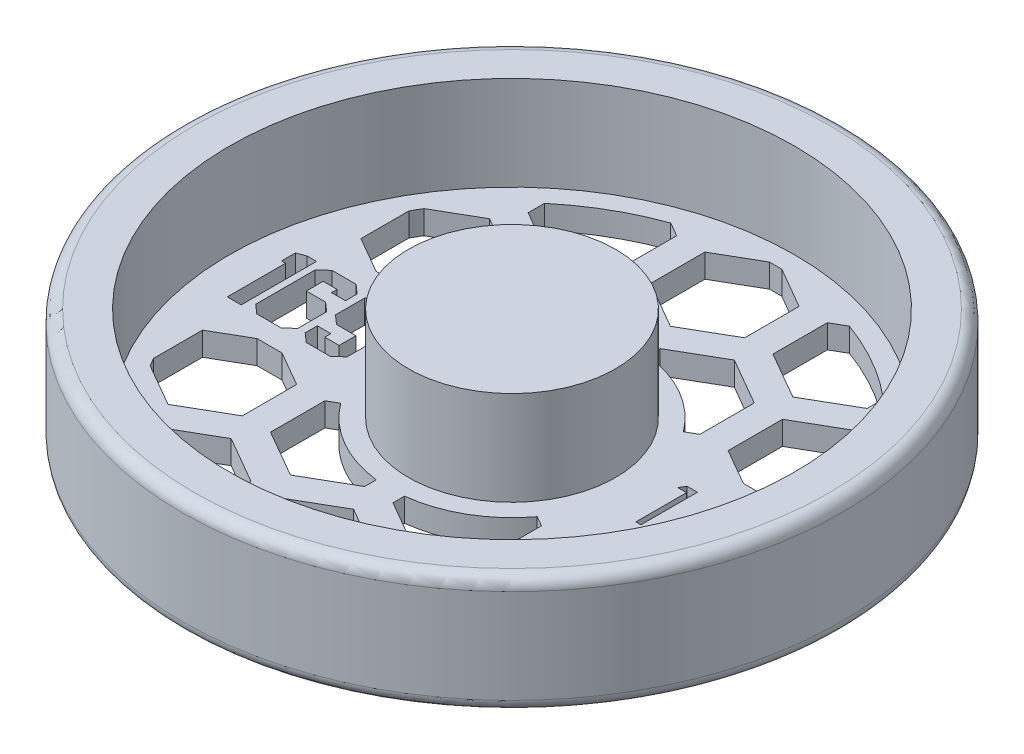
from build123d import *

# Parameters (mm, degrees)
SKETCH2_W               = 1.935420596
SKETCH2_H               = 2.263100716
SKETCH2_W_2             = 1.881765372
CUT_EXTRUDE1_DEPTH      = 65.131856448
CUT_EXTRUDE1_DEPTH_BACK = 65.131856448
CUT_EXTRUDE4_DEPTH      = 65.131856448
CUT_EXTRUDE4_DEPTH_BACK = 65.131856448


with BuildPart() as part:
    # Sketch1 → Revolve1 (revolve)
    with BuildSketch(Plane.XY, mode=Mode.PRIVATE) as revolve1_sk:
        with BuildLine():
            Line((0, 0), (0, 15.875))
            Line((0, 15.875), (13.97, 15.875))
            Line((13.97, 15.875), (13.97, 3.175))
            Line((13.97, 3.175), (38.1, 3.175))
            Line((38.1, 3.175), (38.1, 15.875))
            Line((38.1, 15.875), (42.8625, 15.875))
            ThreePointArc((42.8625, 15.875), (43.985032015, 15.410032015), (44.45, 14.2875))
            Line((44.45, 14.2875), (44.45, 1.5875))
            ThreePointArc((44.45, 1.5875), (43.985032015, 0.464967985), (42.8625, 0))
            Line((42.8625, 0), (0, 0))
        make_face()
    revolve(revolve1_sk.sketch.rotate(Axis((0, 0, 0), (0, 1, 0)), 90), axis=Axis((0, 0, 0), (0, 1, 0)))

    # Sketch2 → Cut-Extrude1 (cut, two sides)
    with BuildSketch(Plane(origin=(0, 3.175, 0), x_dir=(1, 0, 0), z_dir=(0, 1, 0))) as cut_extrude1_sk:
        Polygon((-18.235829876, -4.018393059), (-19.437323651, -5.08), (-22.671967182, -5.08), (-23.875377216, -4.018393059), (-23.875377216, -2.383824972), (-22.045350811, -2.383824972), (-22.045350811, -3.203983402), (-20.109930215, -3.203983402), (-20.109930215, -0.940882686), (-22.729454923, -0.940882686), (-23.927116183, 0.120724255), (-23.927116183, 4.012644285), (-22.729454923, 5.08), (-19.450737458, 5.08), (-18.235829876, 4.006895511), align=None)
        with Locations((-21.077640513, 2.072433044)):
            Rectangle(SKETCH2_W, SKETCH2_H, mode=Mode.SUBTRACT)
        Polygon((-24.883328932, -4.018393059), (-26.086738966, -5.08), (-29.346293851, -5.08), (-30.549703885, -4.018393059), (-30.549703885, 4.012644285), (-29.359707657, 5.08), (-26.105901547, 5.08), (-24.902491513, 4.012644285), (-24.902491513, 2.441312712), (-26.784256884, 2.441312712), (-26.784256884, 3.203983402), (-28.673687288, 3.203983402), (-28.673687288, 0.940882686), (-26.086738966, 0.940882686), (-24.883328932, -0.113059223), align=None)
        with Locations((-27.732804602, -2.072433044)):
            Rectangle(SKETCH2_W_2, SKETCH2_H, mode=Mode.SUBTRACT)
        Polygon((-31.448428895, -5.08), (-33.324445492, -5.08), (-33.324445492, 2.770909091), (-33.860997737, 2.770909091), (-33.860997737, 4.646925688), (-32.703577895, 5.08), (-31.448428895, 5.08), align=None)
        Polygon((19.790324519, 3.81), (21.199230769, 3.81), (21.199230769, -3.81), (20.515384615, -3.81), (20.515384615, 3.028461538), (19.343076923, 3.028461538), align=None)
        Polygon((28.037692308, 4.005384615), (24.850480769, -4.884615385), (24.13, -4.884615385), (27.317211538, 4.005384615), align=None)
        with BuildLine():
            Line((29.600769231, 1.465384615), (28.916923077, 1.465384615))
            add(Edge.make_bspline(
                [(28.916923077, 1.465384615), (28.921380021, 1.556108091), (28.930133342, 1.734286583), (28.971125217, 1.994071773), (29.029779356, 2.242385364), (29.112709893, 2.477233576), (29.215702418, 2.700692922), (29.339211791, 2.911875814), (29.485502403, 3.10997663), (29.65141535, 3.293158912), (29.831614501, 3.46120728), (30.026046289, 3.606325266), (30.23036032, 3.728936882), (30.443936726, 3.831439471), (30.669185153, 3.908379365), (30.904061546, 3.96546762), (31.149597838, 3.999814978), (31.316889543, 4.003506946), (31.401971154, 4.005384615)],
                knots=[0, 0, 0, 0, 1.10065271, 2.161652631, 3.183658789, 4.190468796, 5.17591951, 6.163126047, 7.15150782, 8.156236427, 9.156009102, 10.134482811, 11.092018607, 12.041330605, 13.001268258, 13.972401359, 14.968799086, 16, 16, 16, 16], degree=3))
            add(Edge.make_bspline(
                [(31.401971154, 4.005384615), (31.485525704, 4.003428547), (31.64970741, 3.999584944), (31.889328138, 3.966577217), (32.117443276, 3.914879672), (32.333606928, 3.842347251), (32.536094417, 3.744845155), (32.726426874, 3.627720228), (32.906870239, 3.492258766), (33.069299865, 3.33277475), (33.218451741, 3.162516987), (33.347125793, 2.980751894), (33.457317881, 2.79301842), (33.549166487, 2.597885022), (33.616780138, 2.393514383), (33.668113265, 2.182881901), (33.697128948, 1.963807313), (33.701582128, 1.815529611), (33.703846154, 1.740144231)],
                knots=[0, 0, 0, 0, 1.111607364, 2.184268762, 3.212621178, 4.221274766, 5.211760367, 6.196651075, 7.1921475, 8.207485113, 9.220403448, 10.201281604, 11.166441695, 12.114753415, 13.065576456, 14.026450734, 14.996634279, 16, 16, 16, 16], degree=3))
            add(Edge.make_bspline(
                [(33.703846154, 1.740144231), (33.700159679, 1.634013231), (33.692851421, 1.42361368), (33.630336121, 1.114427036), (33.53269886, 0.814866506), (33.4151389, 0.57377558), (33.296544607, 0.379501517), (33.189674091, 0.21954965), (33.064564988, 0.047325745), (32.919396373, -0.136593487), (32.757171205, -0.333648657), (32.576420095, -0.543720726), (32.375854114, -0.764639265), (32.235083321, -0.91552746), (32.162139423, -0.993713942)],
                knots=[0, 0, 0, 0, 1.184426356, 2.348067706, 3.509069118, 4.696110526, 5.333549288, 6.050745305, 6.844228056, 7.710549037, 8.667450064, 9.695053472, 10.805634456, 12, 12, 12, 12], degree=3))
            Line((32.162139423, -0.993713942), (30.255612981, -3.028461538))
            Line((30.255612981, -3.028461538), (33.801538462, -3.028461538))
            Line((33.801538462, -3.028461538), (33.801538462, -3.81))
            Line((33.801538462, -3.81), (28.623846154, -3.81))
            Line((28.623846154, -3.81), (31.579038462, -0.656370192))
            add(Edge.make_bspline(
                [(31.579038462, -0.656370192), (31.650988432, -0.581262451), (31.789189601, -0.43699585), (31.984659097, -0.226372605), (32.160221694, -0.030975034), (32.317013846, 0.14882768), (32.451634221, 0.315665551), (32.571098909, 0.464135162), (32.666818281, 0.600760566), (32.770701514, 0.759127274), (32.871315954, 0.952484376), (32.957775426, 1.188777722), (33.01049461, 1.432023912), (33.016818852, 1.596402633), (33.02, 1.679086538)],
                knots=[0, 0, 0, 0, 1.329631726, 2.553950428, 3.673215718, 4.687767853, 5.603093632, 6.413772471, 7.123043292, 7.734684054, 8.834405432, 9.900288307, 10.943827018, 12, 12, 12, 12], degree=3))
            add(Edge.make_bspline(
                [(33.02, 1.679086538), (33.018615898, 1.731079754), (33.015888099, 1.833548399), (32.991813912, 1.983783794), (32.955432753, 2.128704903), (32.903300506, 2.268757497), (32.834488117, 2.402533459), (32.750726073, 2.530195631), (32.654082564, 2.653615606), (32.542283514, 2.769337929), (32.419467577, 2.875323868), (32.289722382, 2.969211163), (32.152453298, 3.047673455), (32.008239089, 3.111993869), (31.85748181, 3.162449985), (31.699889879, 3.197411806), (31.535898735, 3.219362814), (31.423920667, 3.222332811), (31.366862981, 3.223846154)],
                knots=[0, 0, 0, 0, 0.991446411, 1.95395049, 2.89581595, 3.838931463, 4.798493298, 5.75982156, 6.748411868, 7.785213223, 8.824556874, 9.840280684, 10.836137867, 11.835679398, 12.848801643, 13.863922112, 14.911575587, 16, 16, 16, 16], degree=3))
            add(Edge.make_bspline(
                [(31.366862981, 3.223846154), (31.307272768, 3.222289426), (31.190247429, 3.219232271), (31.01842942, 3.197846928), (30.854521527, 3.160953413), (30.698111441, 3.110494482), (30.548934514, 3.046359013), (30.407716224, 2.966475843), (30.274773591, 2.871152923), (30.149856703, 2.763078341), (30.034764268, 2.642752877), (29.933642784, 2.508619186), (29.845285588, 2.363126356), (29.768194628, 2.206666963), (29.705589383, 2.037821305), (29.657750695, 1.857188759), (29.619897046, 1.665553637), (29.607251067, 1.533215824), (29.600769231, 1.465384615)],
                knots=[0, 0, 0, 0, 1.031018746, 2.02475058, 2.990194455, 3.934040569, 4.864654155, 5.795059489, 6.735614925, 7.690564532, 8.649604399, 9.611025574, 10.590972636, 11.591080095, 12.624614302, 13.701020113, 14.821632451, 16, 16, 16, 16], degree=3))
        make_face()
    extrude(amount=CUT_EXTRUDE1_DEPTH, mode=Mode.SUBTRACT)
    extrude(cut_extrude1_sk.sketch, amount=-CUT_EXTRUDE1_DEPTH_BACK, mode=Mode.SUBTRACT)


with BuildPart() as body_2:
    # of the pieces the cut leaves, the one that is kept (cut_extrude1_keep)
    add(part.part.solids().sort_by_distance((0, 0, -42.8625))[0])

    # Sketch3 → Cut-Extrude4 (cut, two sides)
    with BuildSketch(Plane(origin=(0, 3.175, 0), x_dir=(1, 0, 0), z_dir=(0, 1, 0))) as cut_extrude4_sk:
        with BuildLine():
            ThreePointArc((-1.905, -16.399727894), (-8.255, -14.298079416), (-13.250080971, -9.849642341))
            Line((-13.250080971, -9.849642341), (-14.605, -10.631905207))
            Line((-14.605, -10.631905207), (-14.605, -17.964253626))
            Line((-14.605, -17.964253626), (-8.255, -21.630427835))
            Line((-8.255, -21.630427835), (-1.905, -17.964253626))
            Line((-1.905, -17.964253626), (-1.905, -16.399727894))
        make_face()
        with BuildLine():
            Line((14.605, -10.631905207), (13.250080971, -9.849642341))
            ThreePointArc((13.250080971, -9.849642341), (8.255, -14.298079416), (1.905, -16.399727894))
            Line((1.905, -16.399727894), (1.905, -17.964253626))
            Line((1.905, -17.964253626), (8.255, -21.630427835))
            Line((8.255, -21.630427835), (14.605, -17.964253626))
            Line((14.605, -17.964253626), (14.605, -10.631905207))
        make_face()
        with BuildLine():
            Line((-18.415, -10.631905207), (-23.081846715, -7.9375))
            Line((-23.081846715, -7.9375), (-26.448153285, -7.9375))
            Line((-26.448153285, -7.9375), (-31.115, -10.631905207))
            Line((-31.115, -10.631905207), (-31.115, -17.215410974))
            ThreePointArc((-31.115, -17.215410974), (-30.795863359, -17.78), (-30.46648324, -18.338674952))
            Line((-30.46648324, -18.338674952), (-24.765, -21.630427835))
            Line((-24.765, -21.630427835), (-18.415, -17.964253626))
            Line((-18.415, -17.964253626), (-18.415, -10.631905207))
        make_face()
        with BuildLine():
            Line((26.448153285, -7.9375), (23.081846715, -7.9375))
            Line((23.081846715, -7.9375), (18.415, -10.631905207))
            Line((18.415, -10.631905207), (18.415, -17.964253626))
            Line((18.415, -17.964253626), (24.765, -21.630427835))
            Line((24.765, -21.630427835), (30.46648324, -18.338674952))
            ThreePointArc((30.46648324, -18.338674952), (30.795863359, -17.78), (31.115, -17.215410974))
            Line((31.115, -17.215410974), (31.115, -10.631905207))
            Line((31.115, -10.631905207), (26.448153285, -7.9375))
        make_face()
        with BuildLine():
            Line((-14.605, 10.737746374), (-13.194804504, 9.923569625))
            ThreePointArc((-13.194804504, 9.923569625), (-8.214997291, 14.321100499), (-1.905, 16.399727894))
            Line((-1.905, 16.399727894), (-1.905, 18.070094793))
            Line((-1.905, 18.070094793), (-8.255, 21.736269002))
            Line((-8.255, 21.736269002), (-14.605, 18.070094793))
            Line((-14.605, 18.070094793), (-14.605, 10.737746374))
        make_face()
        with BuildLine():
            ThreePointArc((1.905, 16.399727894), (8.214997291, 14.321100499), (13.194804504, 9.923569625))
            Line((13.194804504, 9.923569625), (14.605, 10.737746374))
            Line((14.605, 10.737746374), (14.605, 18.070094793))
            Line((14.605, 18.070094793), (8.255, 21.736269002))
            Line((8.255, 21.736269002), (1.905, 18.070094793))
            Line((1.905, 18.070094793), (1.905, 16.399727894))
        make_face()
        with BuildLine():
            Line((-26.264831006, 7.9375), (-23.265168994, 7.9375))
            Line((-23.265168994, 7.9375), (-18.415, 10.737746374))
            Line((-18.415, 10.737746374), (-18.415, 18.070094793))
            Line((-18.415, 18.070094793), (-24.765, 21.736269002))
            Line((-24.765, 21.736269002), (-30.367930984, 18.50141529))
            ThreePointArc((-30.367930984, 18.50141529), (-30.748189416, 17.862319212), (-31.115, 17.215410974))
            Line((-31.115, 17.215410974), (-31.115, 10.737746374))
            Line((-31.115, 10.737746374), (-26.264831006, 7.9375))
        make_face()
        with BuildLine():
            Line((18.415, 10.737746374), (23.265168994, 7.9375))
            Line((23.265168994, 7.9375), (26.264831006, 7.9375))
            Line((26.264831006, 7.9375), (31.115, 10.737746374))
            Line((31.115, 10.737746374), (31.115, 17.215410974))
            ThreePointArc((31.115, 17.215410974), (30.748189416, 17.862319212), (30.367930984, 18.50141529))
            Line((30.367930984, 18.50141529), (24.765, 21.736269002))
            Line((24.765, 21.736269002), (18.415, 18.070094793))
            Line((18.415, 18.070094793), (18.415, 10.737746374))
        make_face()
        with BuildLine():
            Line((-22.86, -25.035825791), (-22.86, -27.238465449))
            ThreePointArc((-22.86, -27.238465449), (-17.728085176, -30.825778108), (-12.046523441, -33.457359026))
            Line((-12.046523441, -33.457359026), (-10.16, -32.368174209))
            Line((-10.16, -32.368174209), (-10.16, -25.035825791))
            Line((-10.16, -25.035825791), (-16.51, -21.369651581))
            Line((-16.51, -21.369651581), (-22.86, -25.035825791))
        make_face()
        with BuildLine():
            ThreePointArc((12.046523441, -33.457359026), (17.728085176, -30.825778108), (22.86, -27.238465449))
            Line((22.86, -27.238465449), (22.86, -25.035825791))
            Line((22.86, -25.035825791), (16.51, -21.369651581))
            Line((16.51, -21.369651581), (10.16, -25.035825791))
            Line((10.16, -25.035825791), (10.16, -32.368174209))
            Line((10.16, -32.368174209), (12.046523441, -33.457359026))
        make_face()
        with BuildLine():
            Line((-6.35, -32.368174209), (-0.838730155, -35.550107338))
            ThreePointArc((-0.838730155, -35.550107338), (0, -35.56), (0.838730155, -35.550107338))
            Line((0.838730155, -35.550107338), (6.35, -32.368174209))
            Line((6.35, -32.368174209), (6.35, -25.035825791))
            Line((6.35, -25.035825791), (0, -21.369651581))
            Line((0, -21.369651581), (-6.35, -25.035825791))
            Line((-6.35, -25.035825791), (-6.35, -32.368174209))
        make_face()
        with BuildLine():
            ThreePointArc((-12.046523441, 33.457359026), (-17.728085176, 30.825778108), (-22.86, 27.238465449))
            Line((-22.86, 27.238465449), (-22.86, 25.035825791))
            Line((-22.86, 25.035825791), (-16.51, 21.369651581))
            Line((-16.51, 21.369651581), (-10.16, 25.035825791))
            Line((-10.16, 25.035825791), (-10.16, 32.368174209))
            Line((-10.16, 32.368174209), (-12.046523441, 33.457359026))
        make_face()
        with BuildLine():
            Line((22.86, 25.035825791), (22.86, 27.238465449))
            ThreePointArc((22.86, 27.238465449), (17.728085176, 30.825778108), (12.046523441, 33.457359026))
            Line((12.046523441, 33.457359026), (10.16, 32.368174209))
            Line((10.16, 32.368174209), (10.16, 25.035825791))
            Line((10.16, 25.035825791), (16.51, 21.369651581))
            Line((16.51, 21.369651581), (22.86, 25.035825791))
        make_face()
        with BuildLine():
            ThreePointArc((0.838730155, 35.550107338), (0, 35.56), (-0.838730155, 35.550107338))
            Line((-0.838730155, 35.550107338), (-6.35, 32.368174209))
            Line((-6.35, 32.368174209), (-6.35, 25.035825791))
            Line((-6.35, 25.035825791), (0, 21.369651581))
            Line((0, 21.369651581), (6.35, 25.035825791))
            Line((6.35, 25.035825791), (6.35, 32.368174209))
            Line((6.35, 32.368174209), (0.838730155, 35.550107338))
        make_face()
    extrude(amount=CUT_EXTRUDE4_DEPTH, mode=Mode.SUBTRACT)
    extrude(cut_extrude4_sk.sketch, amount=-CUT_EXTRUDE4_DEPTH_BACK, mode=Mode.SUBTRACT)


solid = body_2.part
